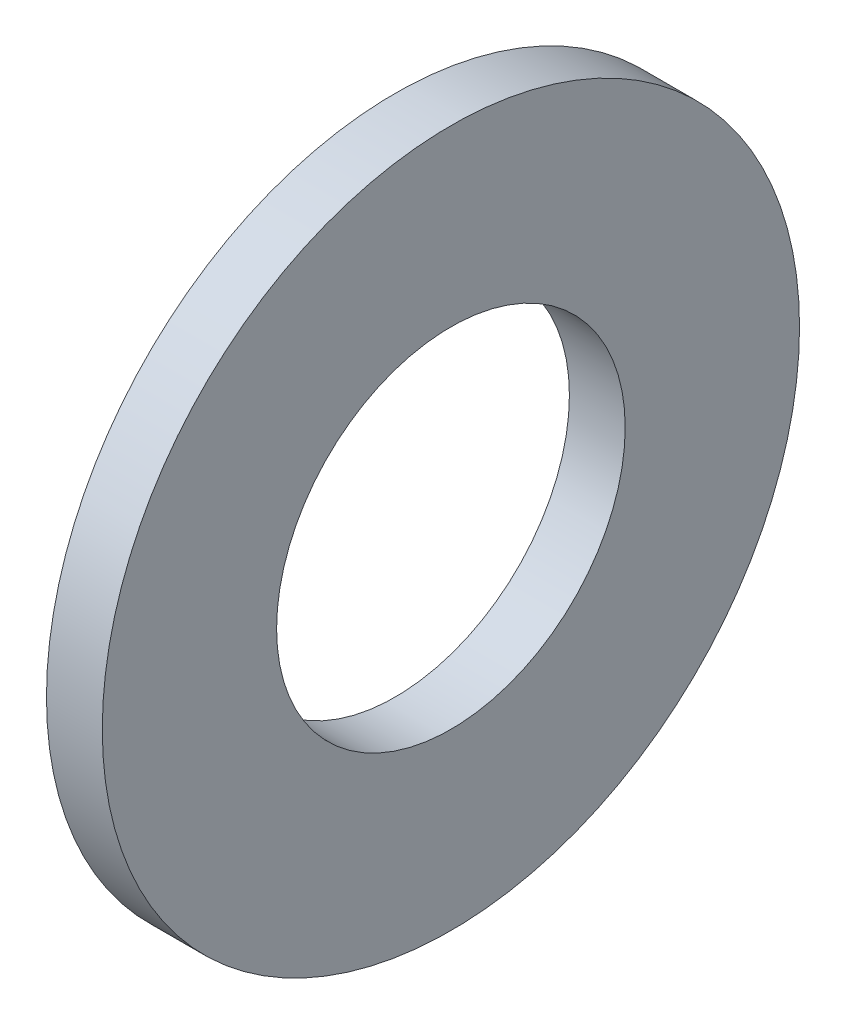
from build123d import *

# Parameters (mm, degrees)
SKETCH1_R           = 0.406
SKETCH1_R_2         = 0.203
BOSS_EXTRUDE1_DEPTH = 0.0325


with BuildPart() as part:
    # Sketch1 → Boss-Extrude1 (new body, symmetric)
    with BuildSketch(Plane(origin=(0, 0, 0), x_dir=(0, 0, -1), z_dir=(1, 0, 0))):
        Circle(SKETCH1_R)
        Circle(SKETCH1_R_2, mode=Mode.SUBTRACT)
    extrude(amount=BOSS_EXTRUDE1_DEPTH, both=True)


solid = part.part
